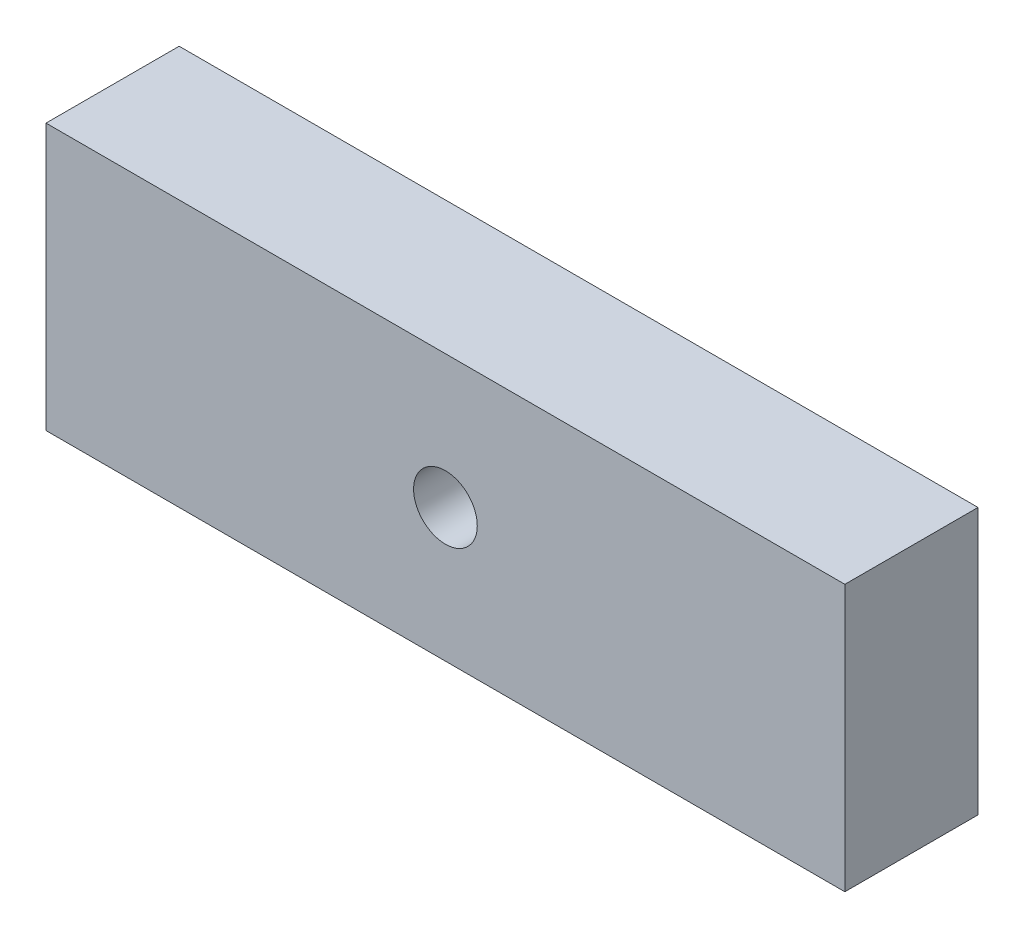
from build123d import *

# Parameters (mm, degrees)
SKETCH1_W                 = 47.625
SKETCH1_H                 = 15.875
BOSS_EXTRUDE1_DEPTH       = 7.9375
F_6_CLEARANCE_HOLE1_D     = 3.7973
F_6_CLEARANCE_HOLE1_DEPTH = 7.9375


with BuildPart() as part:
    # Sketch1 → Boss-Extrude1 (new body)
    with BuildSketch(Plane.XY):
        with Locations((23.8125, 7.9375)):
            Rectangle(SKETCH1_W, SKETCH1_H)
    extrude(amount=BOSS_EXTRUDE1_DEPTH)

    # #6 Clearance Hole1
    with Locations(Plane.XY.offset(7.9375)):
        with Locations((23.8125, 7.9375)):
            Hole(F_6_CLEARANCE_HOLE1_D / 2, depth=F_6_CLEARANCE_HOLE1_DEPTH)


solid = part.part
